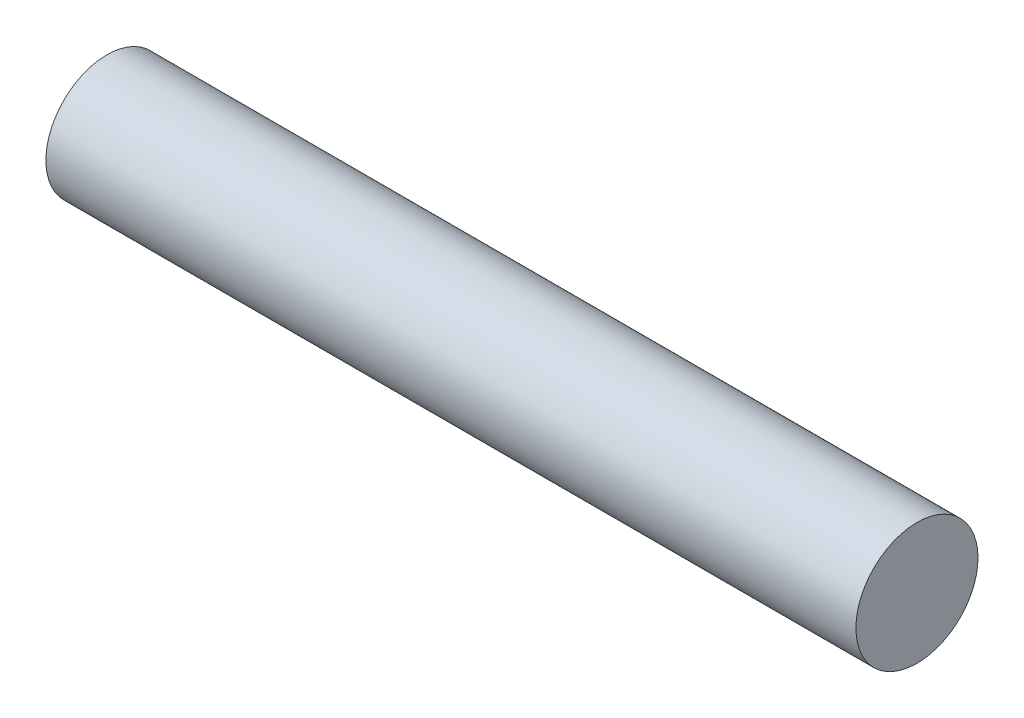
from build123d import *

# Parameters (mm, degrees)
SKETCH1_R           = 7
BOSS_EXTRUDE1_DEPTH = 92.9


with BuildPart() as part:
    # Sketch1 → Boss-Extrude1 (new body)
    with BuildSketch(Plane(origin=(0, 0, 0), x_dir=(0, 0, -1), z_dir=(1, 0, 0))):
        Circle(SKETCH1_R)
    extrude(amount=BOSS_EXTRUDE1_DEPTH)


solid = part.part
